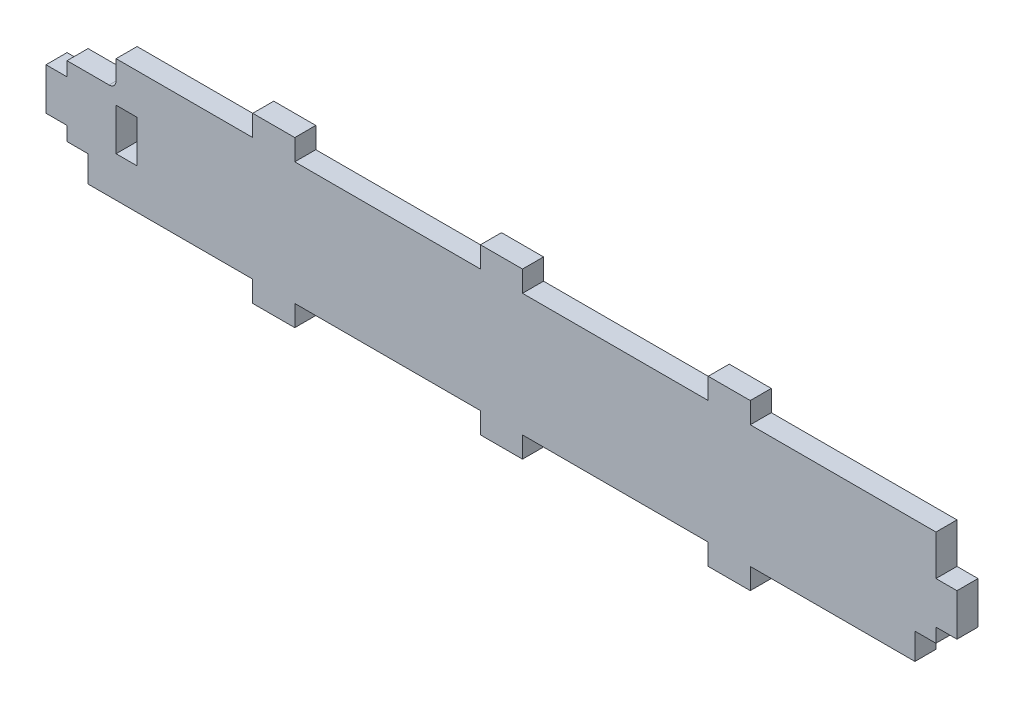
from build123d import *

# Parameters (mm, degrees)
SKETCH1_W           = 260
SKETCH1_H           = 47
BOSS_EXTRUDE1_DEPTH = 6
SKETCH3_W           = 6
SKETCH3_H           = 17.5
SKETCH3_H_2         = 7.5
CUT_EXTRUDE1_DEPTH  = 7
SKETCH4_W           = 53
SKETCH4_H           = 6
CUT_EXTRUDE2_DEPTH  = 7
SKETCH5_W           = 14
SKETCH5_H           = 7.5
SKETCH5_W_2         = 6
SKETCH5_H_2         = 12
CUT_EXTRUDE3_DEPTH  = 7
FILLET1_R           = 2


with BuildPart() as part:
    # Sketch1 → Boss-Extrude1 (new body)
    with BuildSketch(Plane.XY):
        Rectangle(SKETCH1_W, SKETCH1_H)
    extrude(amount=-BOSS_EXTRUDE1_DEPTH)

    # Sketch3 → Cut-Extrude1 (cut, through all)
    with BuildSketch(Plane.XY):
        with Locations((-127, 14.75)):
            Rectangle(SKETCH3_W, SKETCH3_H)
        Polygon((-124, -6), (-130, -6), (-130, -23.5), (-124, -23.5), (-124, -17.5), (-124, -10), align=None)
        with Locations((-121, -13.75)):
            Rectangle(SKETCH3_W, SKETCH3_H_2)
    cut_extrude1 = extrude(amount=-CUT_EXTRUDE1_DEPTH, mode=Mode.SUBTRACT)

    # Mirror1: Cut-Extrude1 across plane
    add(cut_extrude1.mirror(Plane(origin=(0, 0, 0), x_dir=(0, 0, 1), z_dir=(1, 0, 0))), mode=Mode.SUBTRACT)

    # Sketch4 → Cut-Extrude2 (cut, through all)
    with BuildSketch(Plane.XY):
        Polygon((-118, -17.5), (-124, -17.5), (-124, -23.5), (-71, -23.5), (-71, -17.5), align=None)
        with Locations((-32.5, -20.5)):
            Rectangle(SKETCH4_W, SKETCH4_H)
        with Locations((32.5, -20.5)):
            Rectangle(SKETCH4_W, SKETCH4_H)
        Polygon((71, -17.5), (71, -23.5), (124, -23.5), (124, -17.5), (118, -17.5), align=None)
    cut_extrude2 = extrude(amount=-CUT_EXTRUDE2_DEPTH, mode=Mode.SUBTRACT)

    # Mirror2: Cut-Extrude2 across plane
    add(cut_extrude2.mirror(Plane.ZX), mode=Mode.SUBTRACT)

    # Sketch5 → Cut-Extrude3 (cut, through all)
    with BuildSketch(Plane.XY):
        with Locations((-117, 13.75)):
            Rectangle(SKETCH5_W, SKETCH5_H)
        with Locations((-107, 0)):
            Rectangle(SKETCH5_W_2, SKETCH5_H_2)
    extrude(amount=-CUT_EXTRUDE3_DEPTH, mode=Mode.SUBTRACT)

    # Fillet1
    fillet1_edges = [part.edges().sort_by_distance(p)[0] for p in [
        (-110, 10, -3),
    ]]
    fillet(fillet1_edges, radius=FILLET1_R)


solid = part.part
